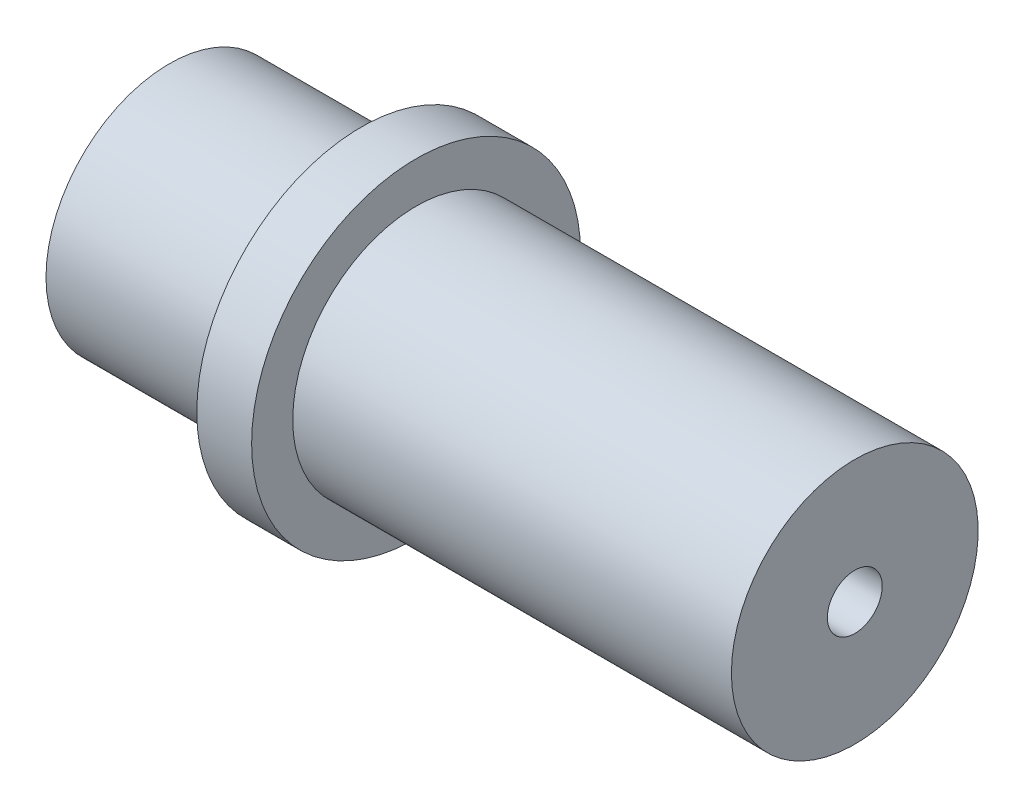
from build123d import *

# Parameters (mm, degrees)
SKETCH2_W          = 8.75
SKETCH2_H          = 5.625
SKETCH2_W_2        = 20
SKETCH3_R          = 1.25
CUT_EXTRUDE1_DEPTH = 31.25
SKETCH4_R          = 1.875
CUT_EXTRUDE2_DEPTH = 21.75


with BuildPart() as part:
    # Sketch2 → Revolve1 (revolve)
    with BuildSketch(Plane(origin=(0, 0, 0), x_dir=(1, 0, 0), z_dir=(0, 1, 0)), mode=Mode.PRIVATE) as revolve1_sk:
        with Locations((-11.25, 2.8125)):
            Rectangle(SKETCH2_W, SKETCH2_H)
        Polygon((-6.875, 5.625), (-6.875, 0), (-4.375, 0), (-4.375, 5.625), (-4.375, 7.5), (-6.875, 7.5), align=None)
        with Locations((5.625, 2.8125)):
            Rectangle(SKETCH2_W_2, SKETCH2_H)
    revolve(revolve1_sk.sketch.rotate(Axis((-15.625, 0, 0), (1, 0, 0)), 180), axis=Axis((-15.625, 0, 0), (1, 0, 0)))

    # Sketch3 → Cut-Extrude1 (cut)
    with BuildSketch(Plane.ZY.offset(15.625)):
        Circle(SKETCH3_R)
    extrude(amount=-CUT_EXTRUDE1_DEPTH, mode=Mode.SUBTRACT)

    # Sketch4 → Cut-Extrude2 (cut)
    with BuildSketch(Plane.ZY.offset(15.625)):
        Circle(SKETCH4_R)
    extrude(amount=-CUT_EXTRUDE2_DEPTH, mode=Mode.SUBTRACT)


solid = part.part
